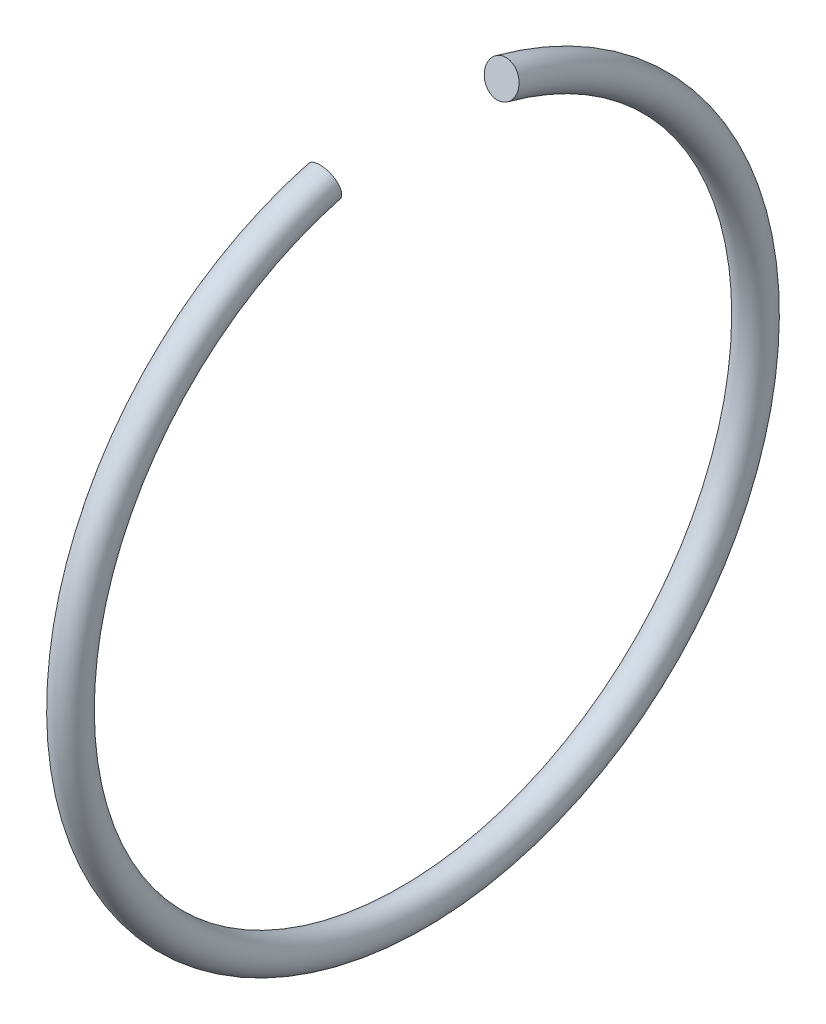
from build123d import *
from build123d.topology import SkipClean

# Parameters (mm, degrees)
SKICA1_R       = 1.6
ROTOVAT1_ANGLE = 330


with BuildPart() as part:
    # Skica1 → Rotovat1 (revolve, symmetric)
    with SkipClean():  # the faces are left unmerged after this step: merging them gives an invalid solid
        with BuildSketch(Plane.XY) as rotovat1_sk:
            with Locations((-113.45, -32.5)):
                Circle(SKICA1_R)
        revolve(axis=Axis((-67.482261058, 0, 0), (-1, 0, 0)), revolution_arc=ROTOVAT1_ANGLE / 2)
        revolve(rotovat1_sk.sketch, axis=Axis((-67.482261058, 0, 0), (1, 0, 0)), revolution_arc=ROTOVAT1_ANGLE / 2)


solid = part.part
